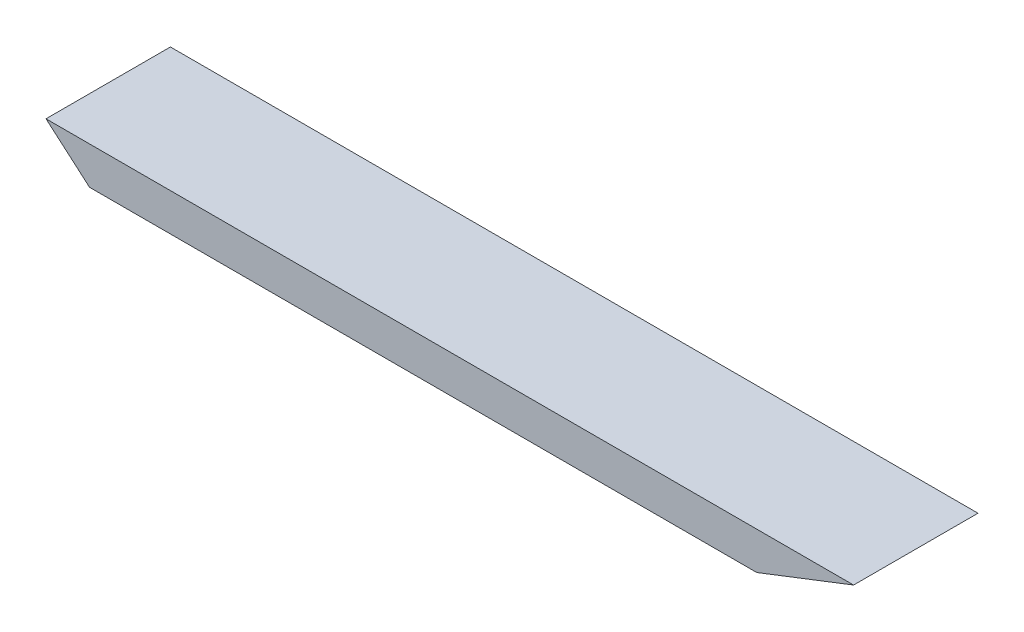
from build123d import *

# Parameters (mm, degrees)
BOSS_EXTRU_1_DEPTH = 6


with BuildPart() as part:
    # Esquisse1 → Boss.-Extru.1 (new body)
    with BuildSketch(Plane.XY):
        Polygon((-14.352152453, 3.644528302), (24.597847547, 3.644528302), (19.928070987, 1.832303633), (-12.251929013, 1.832303633), align=None)
    extrude(amount=BOSS_EXTRU_1_DEPTH)


solid = part.part
